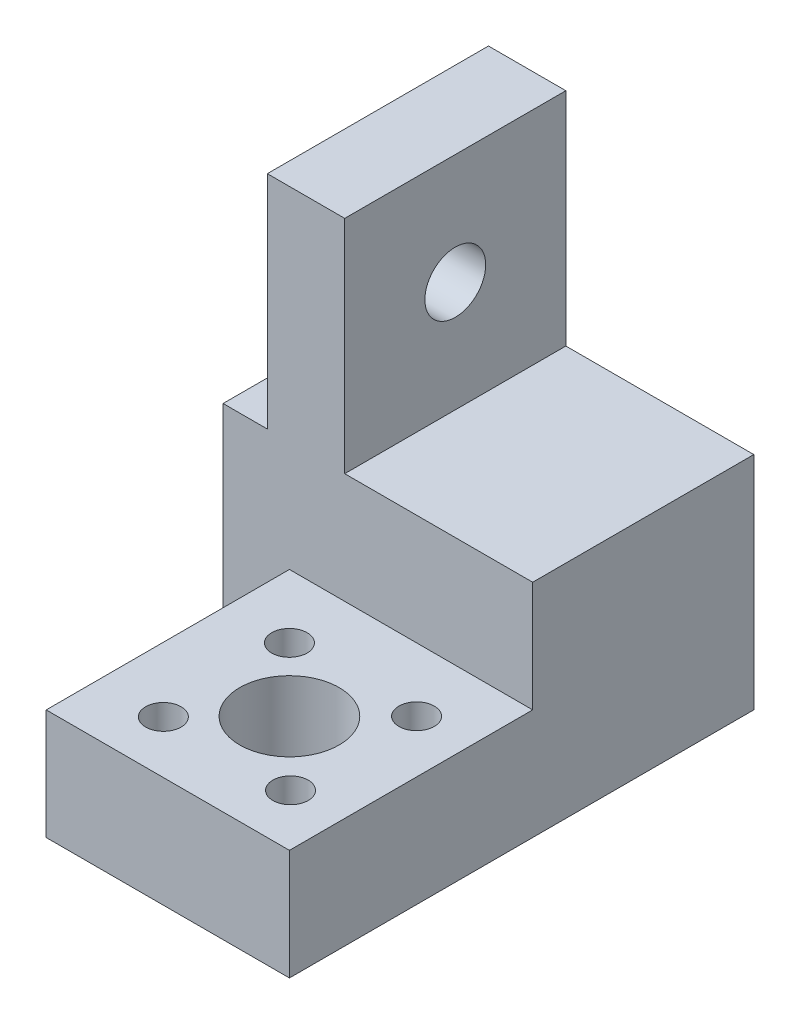
from build123d import *

# Parameters (mm, degrees)
SKETCH1_W           = 22
SKETCH1_H           = 22
SKETCH1_R           = 1.6
BOSS_EXTRUDE1_DEPTH = 10
SKETCH2_W           = 28
SKETCH2_H           = 20
BOSS_EXTRUDE2_DEPTH = 20
SKETCH3_W           = 7
SKETCH3_H           = 20
BOSS_EXTRUDE3_DEPTH = 20
SKETCH4_R           = 2.75
CUT_EXTRUDE1_DEPTH  = 12
SKETCH5_R           = 4.5
CUT_EXTRUDE2_DEPTH  = 11


with BuildPart() as part:
    # Sketch1 → Boss-Extrude1 (new body)
    with BuildSketch(Plane(origin=(0, 0, 0), x_dir=(1, 0, 0), z_dir=(0, 1, 0))):
        Rectangle(SKETCH1_W, SKETCH1_H)
        with Locations((-5.25, 5.25)):
            Circle(SKETCH1_R, mode=Mode.SUBTRACT)
        with Locations((6.25, 5.25)):
            Circle(SKETCH1_R, mode=Mode.SUBTRACT)
        with Locations((6.348618383, -6.25)):
            Circle(SKETCH1_R, mode=Mode.SUBTRACT)
        with Locations((-5.151381617, -6.25)):
            Circle(SKETCH1_R, mode=Mode.SUBTRACT)
    extrude(amount=BOSS_EXTRUDE1_DEPTH)

    # Sketch2 → Boss-Extrude2 (add)
    with BuildSketch(Plane(origin=(0, 0, -11), x_dir=(-1, 0, 0), z_dir=(0, 0, -1))):
        with Locations((3, 10)):
            Rectangle(SKETCH2_W, SKETCH2_H)
    extrude(amount=BOSS_EXTRUDE2_DEPTH)

    # Sketch3 → Boss-Extrude3 (add)
    with BuildSketch(Plane(origin=(0, 20, 0), x_dir=(1, 0, 0), z_dir=(0, 1, 0))):
        with Locations((-9.5, 21)):
            Rectangle(SKETCH3_W, SKETCH3_H)
    extrude(amount=BOSS_EXTRUDE3_DEPTH)

    # Sketch4 → Cut-Extrude1 (cut, through all)
    with BuildSketch(Plane(origin=(-6, 0, 0), x_dir=(0, 0, -1), z_dir=(1, 0, 0))):
        with Locations((21, 30)):
            Circle(SKETCH4_R)
    extrude(amount=-CUT_EXTRUDE1_DEPTH, mode=Mode.SUBTRACT)

    # Sketch5 → Cut-Extrude2 (cut, through all)
    with BuildSketch(Plane(origin=(0, 10, 0), x_dir=(1, 0, 0), z_dir=(0, 1, 0))):
        with Locations((0.5, -0.5)):
            Circle(SKETCH5_R)
    extrude(amount=-CUT_EXTRUDE2_DEPTH, mode=Mode.SUBTRACT)


solid = part.part
